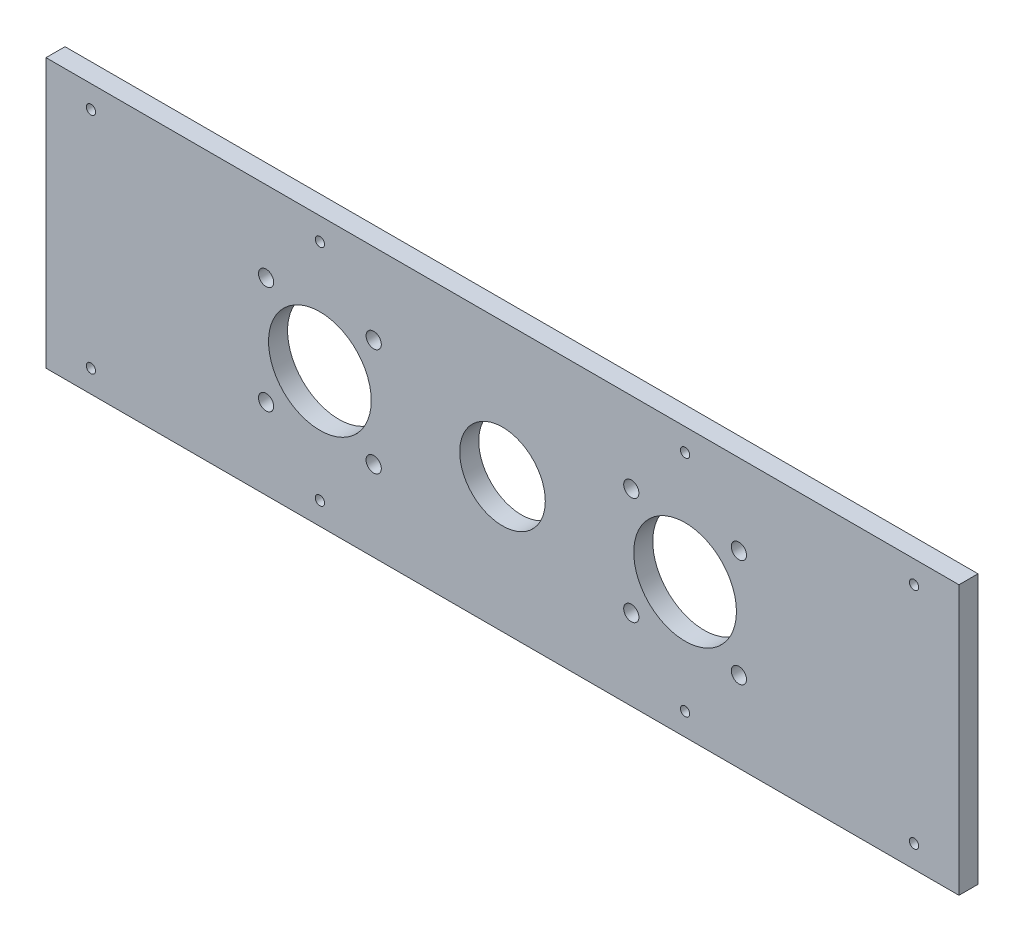
from build123d import *

# Parameters (mm, degrees)
SKETCH1_W           = 304.8
SKETCH1_H           = 89.8
SKETCH1_R           = 14.2875
SKETCH1_R_2         = 2.54
SKETCH1_R_3         = 17.145
BOSS_EXTRUDE1_DEPTH = 6.35
SKETCH2_R           = 1.55
CUT_EXTRUDE1_DEPTH  = 10


with BuildPart() as part:
    # Sketch1 → Boss-Extrude1 (new body)
    with BuildSketch(Plane.XY):
        with Locations((152.4, 44.9)):
            Rectangle(SKETCH1_W, SKETCH1_H)
        with Locations((152.4, 44.9)):
            Circle(SKETCH1_R, mode=Mode.SUBTRACT)
        with Locations((109.401585406, 62.859439014)):
            Circle(SKETCH1_R_2, mode=Mode.SUBTRACT)
        with Locations((109.399439014, 26.938414594)):
            Circle(SKETCH1_R_2, mode=Mode.SUBTRACT)
        with Locations((73.478414594, 26.940560986)):
            Circle(SKETCH1_R_2, mode=Mode.SUBTRACT)
        with Locations((73.480560986, 62.861585406)):
            Circle(SKETCH1_R_2, mode=Mode.SUBTRACT)
        with Locations((91.44, 44.9)):
            Circle(SKETCH1_R_3, mode=Mode.SUBTRACT)
        with Locations((195.400560986, 62.861585406)):
            Circle(SKETCH1_R_2, mode=Mode.SUBTRACT)
        with Locations((231.321585406, 62.859439014)):
            Circle(SKETCH1_R_2, mode=Mode.SUBTRACT)
        with Locations((231.319439014, 26.938414594)):
            Circle(SKETCH1_R_2, mode=Mode.SUBTRACT)
        with Locations((195.398414594, 26.940560986)):
            Circle(SKETCH1_R_2, mode=Mode.SUBTRACT)
        with Locations((213.36, 44.9)):
            Circle(SKETCH1_R_3, mode=Mode.SUBTRACT)
    extrude(amount=BOSS_EXTRUDE1_DEPTH)

    # Sketch2 → Cut-Extrude1 (cut)
    with BuildSketch(Plane(origin=(0, 0, 0), x_dir=(-1, 0, 0), z_dir=(0, 0, -1))):
        with Locations((-289.8, 82.3)):
            Circle(SKETCH2_R)
        with Locations((-213.36, 82.3)):
            Circle(SKETCH2_R)
        with Locations((-91.44, 82.3)):
            Circle(SKETCH2_R)
        with Locations((-15, 82.3)):
            Circle(SKETCH2_R)
        with Locations((-15, 7.5)):
            Circle(SKETCH2_R)
        with Locations((-91.44, 7.5)):
            Circle(SKETCH2_R)
        with Locations((-213.36, 7.5)):
            Circle(SKETCH2_R)
        with Locations((-289.8, 7.5)):
            Circle(SKETCH2_R)
    extrude(amount=-CUT_EXTRUDE1_DEPTH, mode=Mode.SUBTRACT)


solid = part.part
